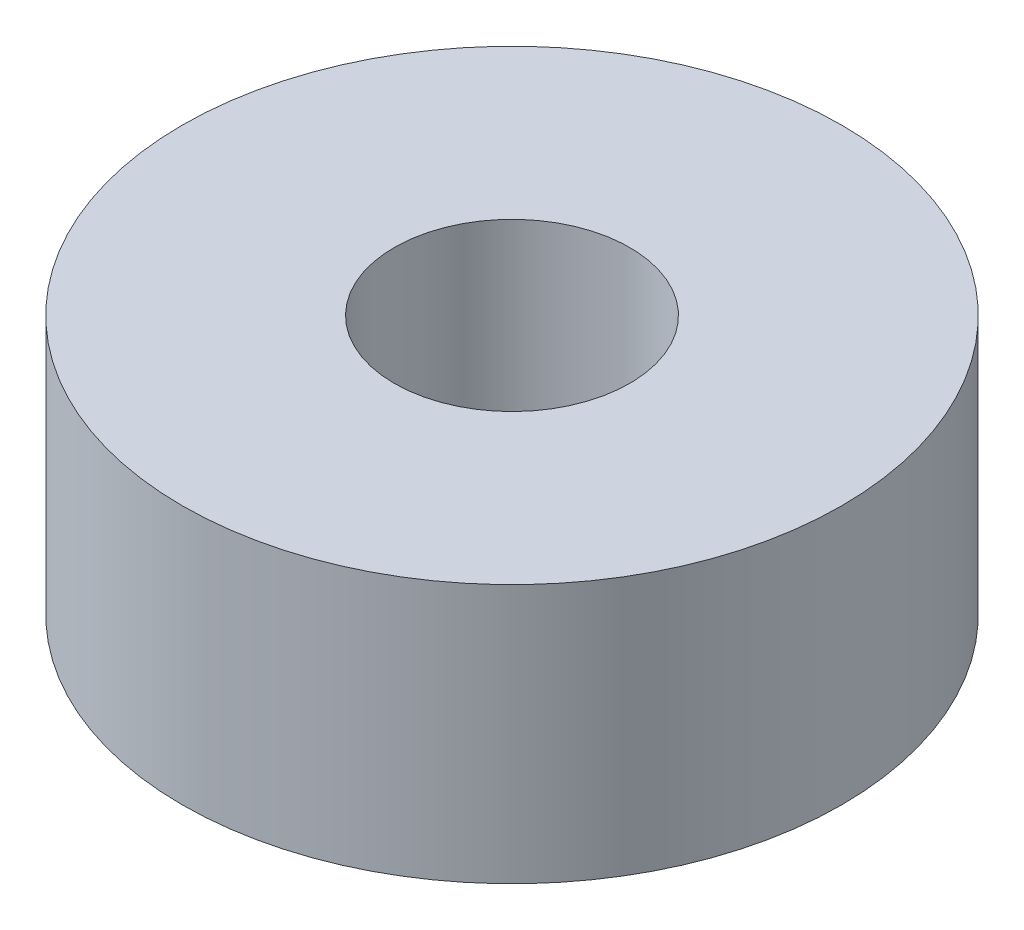
from build123d import *

# Parameters (mm, degrees)
SKETCH1_R           = 11.1125
SKETCH1_R_2         = 3.96875
BOSS_EXTRUDE1_DEPTH = 8.73125


with BuildPart() as part:
    # Sketch1 → Boss-Extrude1 (new body)
    with BuildSketch(Plane(origin=(0, 0, 0), x_dir=(1, 0, 0), z_dir=(0, 1, 0))):
        Circle(SKETCH1_R)
        Circle(SKETCH1_R_2, mode=Mode.SUBTRACT)
    extrude(amount=BOSS_EXTRUDE1_DEPTH)


solid = part.part
